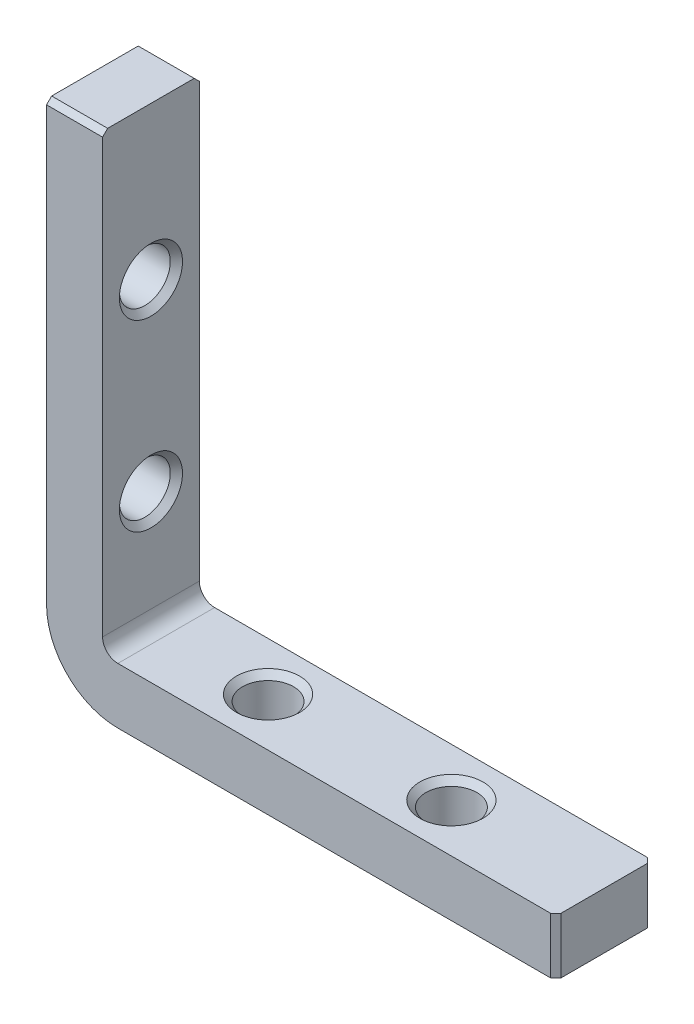
from build123d import *

# Parameters (mm, degrees)
EXTRUDE_1_DEPTH            = 4.75
HOLE_WIZARD_M61_AT_2_COUNT = 2
HOLE_WIZARD_M61_AT_2_PITCH = 18
CHAMFER_1_SIZE             = 0.5


with BuildPart() as part:
    # Эскиз1 → Бобышка-Вытянуть1 (new body, symmetric)
    with BuildSketch(Plane.XY):
        with BuildLine():
            Line((0, 50), (0, 7))
            ThreePointArc((0, 7), (2.050252532, 2.050252532), (7, 0))
            Line((7, 0), (50, 0))
            Line((50, 0), (50, 5.5))
            Line((50, 5.5), (7, 5.5))
            ThreePointArc((7, 5.5), (5.939339828, 5.939339828), (5.5, 7))
            Line((5.5, 7), (5.5, 50))
            Line((5.5, 50), (0, 50))
        make_face()
    extrude(amount=EXTRUDE_1_DEPTH, both=True)

    # Эскиз5 → Отверстие обработанное метчиком M61 (revolve, cut)
    with BuildSketch(Plane.ZX.offset(35)):
        Polygon((0, 0), (0, 5.5), (3.1, 5.5), (2.5, 4.9), (2.5, 0.6), (3.1, 0), align=None)
    hole_wizard_m61 = revolve(axis=Axis((-6.35, 35, 0), (1, 0, 0)), mode=Mode.SUBTRACT)

    # Отверстие обработанное метчиком M61 at 2: Отверстие обработанное метчиком M61 ×2
    with Locations(*[(0, -i * HOLE_WIZARD_M61_AT_2_PITCH, 0) for i in range(1, HOLE_WIZARD_M61_AT_2_COUNT)]):
        add(hole_wizard_m61, mode=Mode.SUBTRACT)

    # Зеркальное отражение1: Отверстие обработанное метчиком M61 across plane
    add(hole_wizard_m61.mirror(Plane(origin=(0, 0, 0), x_dir=(0, 0, 1), z_dir=(-0.707106781, 0.707106781, 0))), mode=Mode.SUBTRACT)

    # Зеркальное отражение1 copy 1 sketch → Зеркальное отражение1 copy 1 (revolve, cut)
    with BuildSketch(Plane(origin=(17, 0, 0), x_dir=(0, 0, 1), z_dir=(1, 0, 0))):
        Polygon((0, 0), (0, -5.5), (3.1, -5.5), (2.5, -4.9), (2.5, -0.6), (3.1, 0), align=None)
    revolve(axis=Axis((17, -6.35, 0), (0, -1, 0)), mode=Mode.SUBTRACT)

    # Фаска1
    chamfer_1_edges = [part.edges().sort_by_distance(p)[0] for p in [
        (2.75, 50, -4.75),
        (50, 2.75, 4.75),
        (2.75, 50, 4.75),
        (50, 2.75, -4.75),
    ]]
    chamfer(chamfer_1_edges, length=CHAMFER_1_SIZE)


solid = part.part
